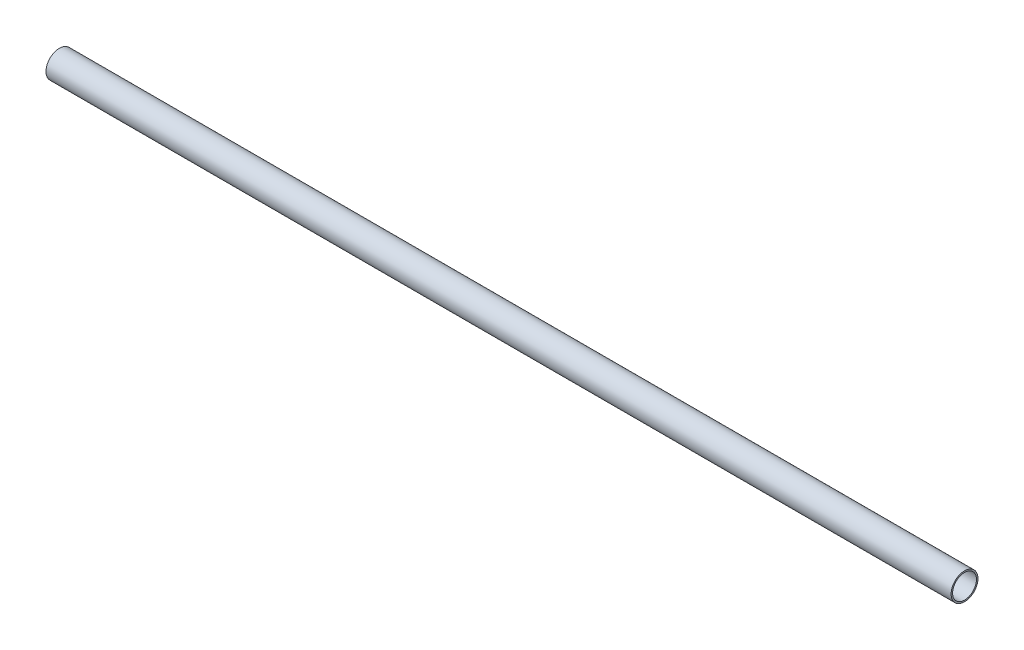
from build123d import *

# Parameters (mm, degrees)
EXTRUDE_THIN1_DEPTH      = 82.55
EXTRUDE_THIN1_DEPTH_BACK = 131.0386
SKETCH1_R                = 3.175
SKETCH1_R_2              = 2.8194


with BuildPart() as part:
    # Sketch1 → Extrude-Thin1 (new, two sides: drawn at the far end of the back side and taken through both)
    with BuildSketch(Plane(origin=(0, 0, 0), x_dir=(0, 0, -1), z_dir=(1, 0, 0)).offset(-EXTRUDE_THIN1_DEPTH_BACK)):
        Circle(SKETCH1_R)
        Circle(SKETCH1_R_2, mode=Mode.SUBTRACT)
    extrude(amount=EXTRUDE_THIN1_DEPTH + EXTRUDE_THIN1_DEPTH_BACK)


solid = part.part
